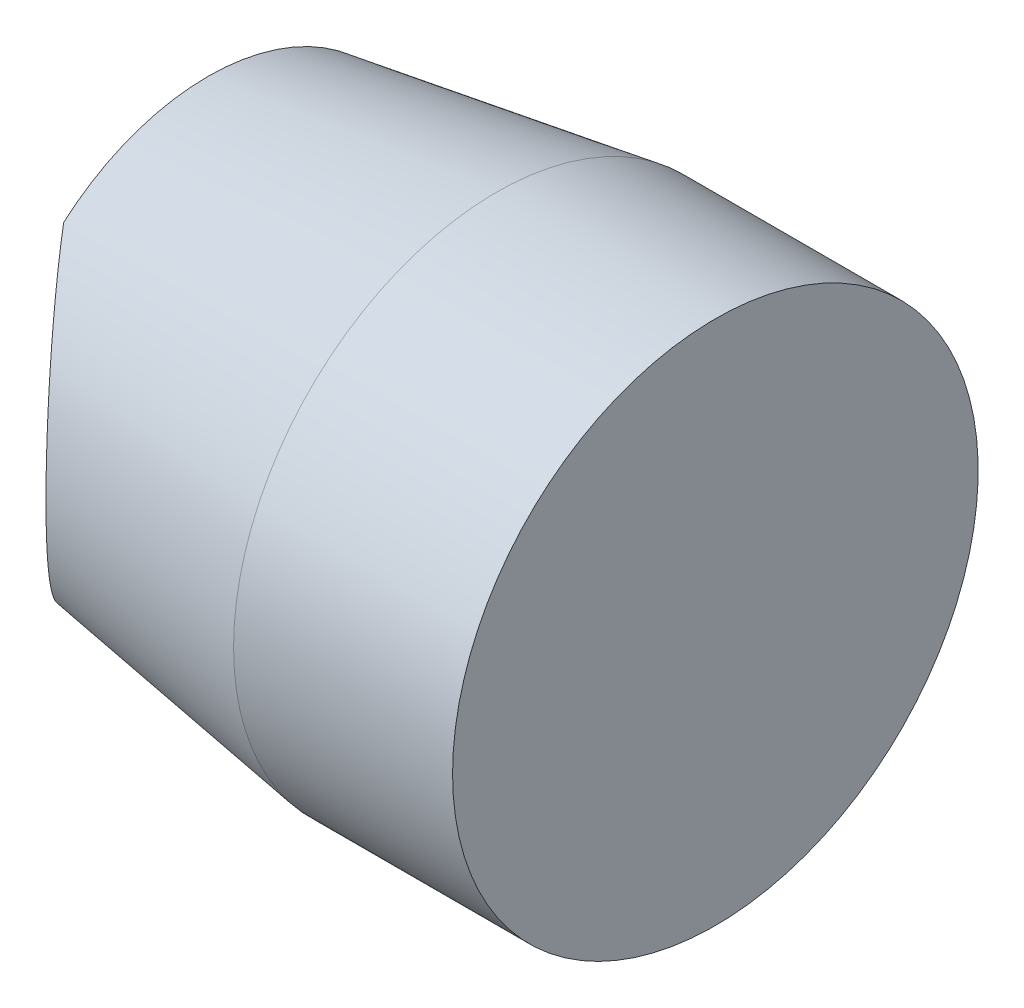
from build123d import *

# Parameters (mm, degrees)
CROQUIS2_R = 3.05


with BuildPart() as part:
    # Croquis1 → Revolución1 (revolve)
    with BuildSketch(Plane.XY):
        Polygon((0, 0), (6.95, 0), (6.95, 3.6), (3.95, 3.6), (0, 3), align=None)
    revolve(axis=Axis((0, 0, 0), (1, 0, 0)))

    # Croquis2 → Cortar-Revolución1 (revolve, cut)
    with BuildSketch(Plane.XY):
        with Locations((-2, 0)):
            Circle(CROQUIS2_R)
    revolve(axis=Axis((-37, 2.569103134, 0), (0, -1, 0)), mode=Mode.SUBTRACT)


solid = part.part
